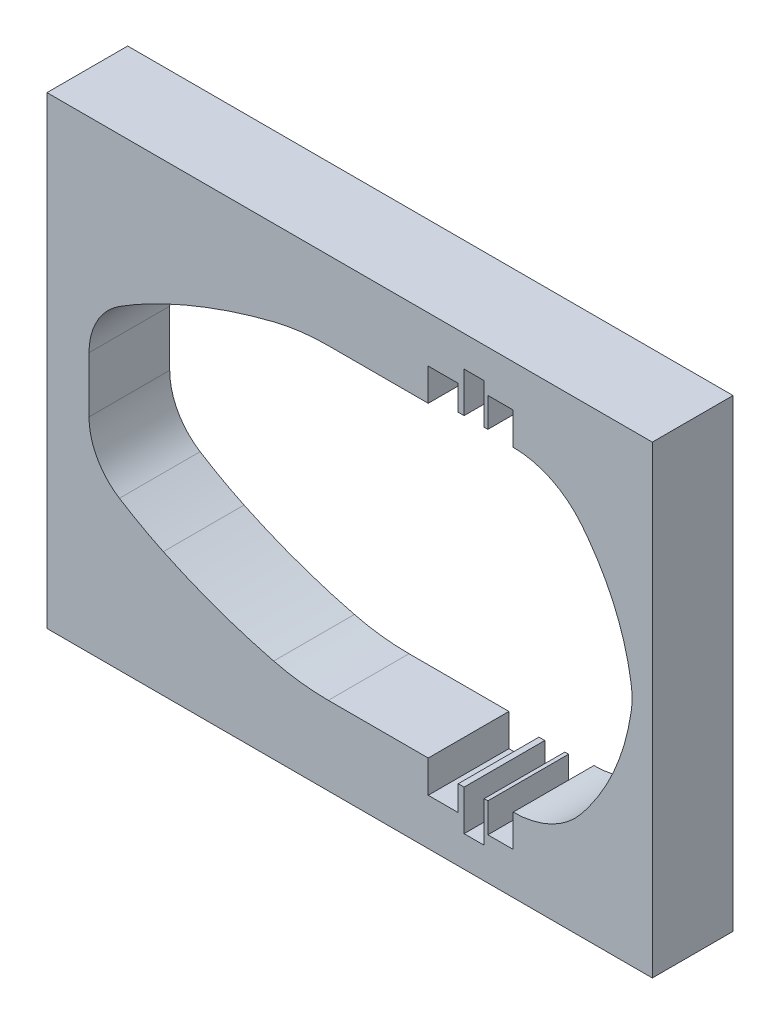
from build123d import *

# Parameters (mm, degrees)
SKETCH_4_W          = 150
SKETCH_4_H          = 115
EXTRUDE_1_DEPTH     = 20
CUT_EXTRUDE_1_DEPTH = 20
SKETCH_6_R          = 5
CUT_EXTRUDE_7_DEPTH = 10
SKETCH_9_R          = 5
CUT_EXTRUDE_8_DEPTH = 5
SKETCH_11_R         = 5
CUT_EXTRUDE_9_DEPTH = 5


with BuildPart() as part:
    # 草圖4 → 填料-伸長1 (new body)
    with BuildSketch(Plane.XY):
        with Locations((17.378483322, 72.59909222)):
            Rectangle(SKETCH_4_W, SKETCH_4_H)
    extrude(amount=EXTRUDE_1_DEPTH)

    # 草圖2 → 除料-伸長1 (cut)
    with BuildSketch(Plane.XY):
        with BuildLine():
            Line((-47.207745562, 65.711609892), (-47.207745562, 79.486574548))
            ThreePointArc((-47.207745562, 79.486574548), (-45.199499918, 87.30172842), (-39.672345291, 93.180524415))
            ThreePointArc((-39.672345291, 93.180524415), (-34.318944815, 96.349970124), (-28.784309893, 99.191114091))
            ThreePointArc((-28.784309893, 99.191114091), (-15.358686248, 104.775217116), (-1.443024263, 108.992316634))
            ThreePointArc((-1.443024263, 108.992316634), (5.275172672, 110.237187628), (12.094993869, 110.654216049))
            Line((12.094993869, 110.654216049), (33.772014803, 110.654216049))
            Line((33.772014803, 110.654216049), (36.848505718, 110.654216049))
            Line((36.848505718, 110.654216049), (36.848505718, 118.654216049))
            Line((36.848505718, 118.654216049), (44.287834674, 118.654216049))
            Line((44.287834674, 118.654216049), (44.287834674, 112.450982223))
            Line((44.287834674, 112.450982223), (45.736024045, 112.450982223))
            Line((45.736024045, 112.450982223), (45.736024045, 122.450982223))
            Line((45.736024045, 122.450982223), (50.704341659, 122.450982223))
            Line((50.704341659, 122.450982223), (50.704341659, 112.450982223))
            Line((50.704341659, 112.450982223), (51.627972578, 112.450982223))
            Line((51.627972578, 112.450982223), (51.627972578, 119.746473649))
            Line((51.627972578, 119.746473649), (57.89832581, 119.746473649))
            Line((57.89832581, 119.746473649), (57.89832581, 111.746473649))
            ThreePointArc((57.89832581, 111.746473649), (67.349215797, 109.578876862), (74.910898446, 103.509383234))
            ThreePointArc((74.910898446, 103.509383234), (75.840394113, 102.31020351), (76.746696007, 101.093399876))
            ThreePointArc((76.746696007, 101.093399876), (83.438828083, 89.130434251), (87.081135301, 75.915640404))
            Line((87.081135301, 75.915640404), (87.182187493, 75.239707939))
            ThreePointArc((87.182187493, 75.239707939), (87.378483322, 72.59909222), (87.182187493, 69.958476501))
            Line((87.182187493, 69.958476501), (87.081135301, 69.282544036))
            ThreePointArc((87.081135301, 69.282544036), (83.438828083, 56.06775019), (76.746696007, 44.104784564))
            ThreePointArc((76.746696007, 44.104784564), (75.840394113, 42.887980931), (74.910898446, 41.688801206))
            ThreePointArc((74.910898446, 41.688801206), (67.349215797, 35.619307578), (57.89832581, 33.451710791))
            Line((57.89832581, 33.451710791), (57.89832581, 25.451710791))
            Line((57.89832581, 25.451710791), (51.627972578, 25.451710791))
            Line((51.627972578, 25.451710791), (51.627972578, 32.747202217))
            Line((51.627972578, 32.747202217), (50.704341659, 32.747202217))
            Line((50.704341659, 32.747202217), (50.704341659, 22.747202217))
            Line((50.704341659, 22.747202217), (45.736024045, 22.747202217))
            Line((45.736024045, 22.747202217), (45.736024045, 32.747202217))
            Line((45.736024045, 32.747202217), (44.287834674, 32.747202217))
            Line((44.287834674, 32.747202217), (44.287834674, 26.543968391))
            Line((44.287834674, 26.543968391), (36.848505718, 26.543968391))
            Line((36.848505718, 26.543968391), (36.848505718, 34.543968391))
            Line((36.848505718, 34.543968391), (33.772014803, 34.543968391))
            Line((33.772014803, 34.543968391), (12.094993869, 34.543968391))
            ThreePointArc((12.094993869, 34.543968391), (5.275172672, 34.960996812), (-1.443024263, 36.205867806))
            ThreePointArc((-1.443024263, 36.205867806), (-15.358686248, 40.422967325), (-28.784309893, 46.007070349))
            ThreePointArc((-28.784309893, 46.007070349), (-34.318944815, 48.848214316), (-39.672345291, 52.017660026))
            ThreePointArc((-39.672345291, 52.017660026), (-45.199499918, 57.89645602), (-47.207745562, 65.711609892))
        make_face()
    extrude(amount=CUT_EXTRUDE_1_DEPTH, mode=Mode.SUBTRACT)

    # 草圖6 → 除料-伸長7 (cut)
    with BuildSketch(Plane(origin=(-57.7, 0, 0), x_dir=(0, 0, -1), z_dir=(1, 0, 0))):
        with Locations((-10, 120.09909222)):
            Circle(SKETCH_6_R)
        with Locations((-10, 105.09909222)):
            Circle(SKETCH_6_R)
        with Locations((-10, 40.09909222)):
            Circle(SKETCH_6_R)
        with Locations((-10, 25.09909222)):
            Circle(SKETCH_6_R)
    extrude(amount=CUT_EXTRUDE_7_DEPTH, mode=Mode.SUBTRACT)

    # 草圖9 → 除料-伸長8 (cut)
    with BuildSketch(Plane(origin=(-57.7, 0, 0), x_dir=(0, 0, -1), z_dir=(1, 0, 0))):
        with Locations((-10, 90.09909222)):
            Circle(SKETCH_9_R)
        with Locations((-10, 55.09909222)):
            Circle(SKETCH_9_R)
    extrude(amount=CUT_EXTRUDE_8_DEPTH, mode=Mode.SUBTRACT)

    # 草圖11 → 除料-伸長9 (cut)
    with BuildSketch(Plane(origin=(-57.7, 0, 0), x_dir=(0, 0, -1), z_dir=(1, 0, 0))):
        with Locations((-10, 72.59909222)):
            Circle(SKETCH_11_R)
    extrude(amount=CUT_EXTRUDE_9_DEPTH, mode=Mode.SUBTRACT)


solid = part.part
